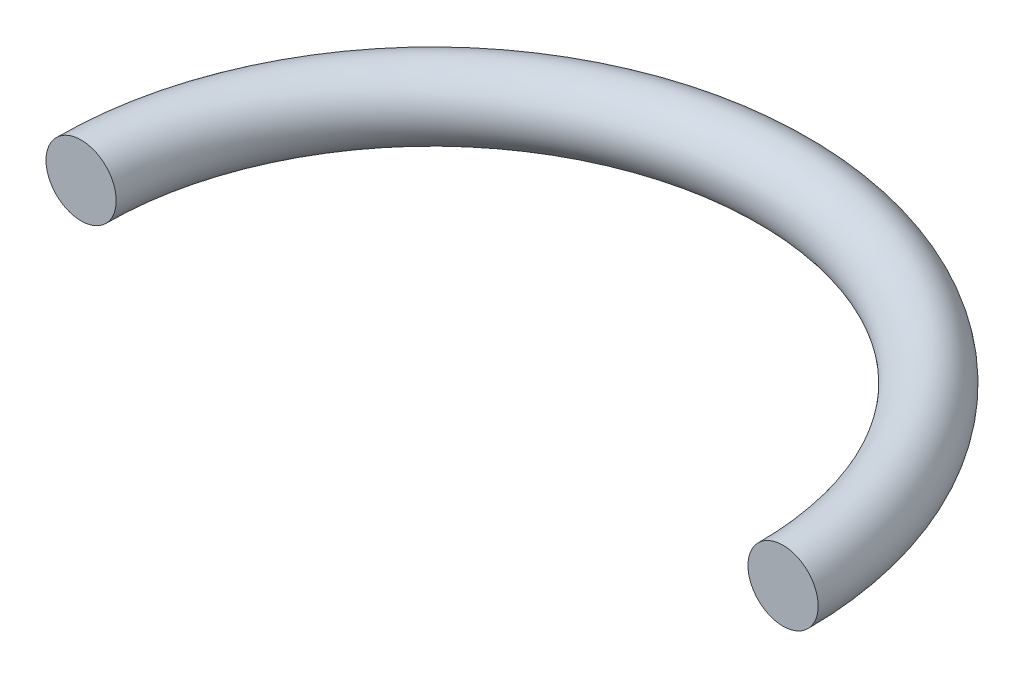
from build123d import *

# Parameters (mm, degrees)
SKETCH1_R      = 5
REVOLVE1_ANGLE = 180


with BuildPart() as part:
    # Sketch1 → Revolve1 (revolve)
    with BuildSketch(Plane.XY):
        with Locations((50, 0)):
            Circle(SKETCH1_R)
    revolve(axis=Axis((0, 0, 0), (0, 1, 0)), revolution_arc=REVOLVE1_ANGLE)


solid = part.part
